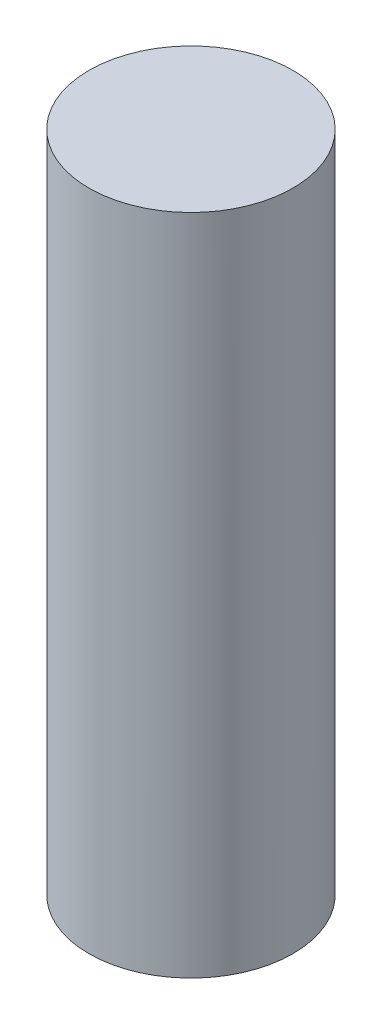
from build123d import *

# Parameters (mm, degrees)
CUT_EXTRUDE1_REACH = 3
SKETCH2_R          = 3
SKETCH2_R_2        = 2


with BuildPart() as part:
    # Sketch1 → Revolve1 (revolve)
    with BuildSketch(Plane.XY):
        Polygon((0, 0), (-3, 0), (-3, 1), (-2, 1), (-2, 13), (0, 13), align=None)
    revolve(axis=Axis((0, 13, 0), (0, -1, 0)))

    # Sketch2 → Cut-Extrude1 (cut, up to next)
    with BuildSketch(Plane(origin=(0, 1, 0), x_dir=(1, 0, 0), z_dir=(0, 1, 0)), mode=Mode.PRIVATE) as cut_extrude1_sk1:
        Circle(SKETCH2_R)
        Circle(SKETCH2_R_2, mode=Mode.SUBTRACT)
    cut_extrude1_tool1 = extrude(cut_extrude1_sk1.sketch, amount=-CUT_EXTRUDE1_REACH, mode=Mode.PRIVATE) & part.part
    add(cut_extrude1_tool1.solids().sort_by_distance((-2.915147, 1, 0))[0], mode=Mode.SUBTRACT)


solid = part.part
